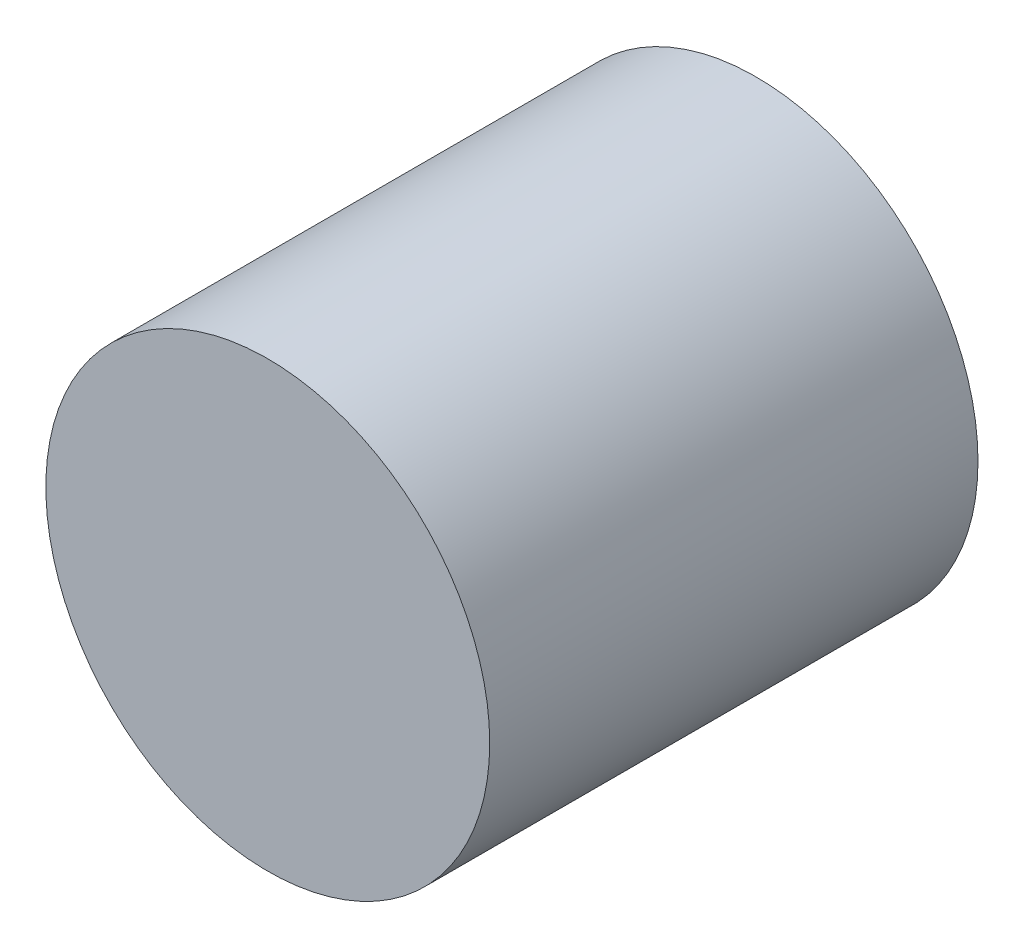
from build123d import *

# Parameters (mm, degrees)
SKETCH1_R           = 5
BOSS_EXTRUDE1_DEPTH = 11


with BuildPart() as part:
    # Sketch1 → Boss-Extrude1 (new body)
    with BuildSketch(Plane.XY):
        Circle(SKETCH1_R)
    extrude(amount=BOSS_EXTRUDE1_DEPTH)


solid = part.part
